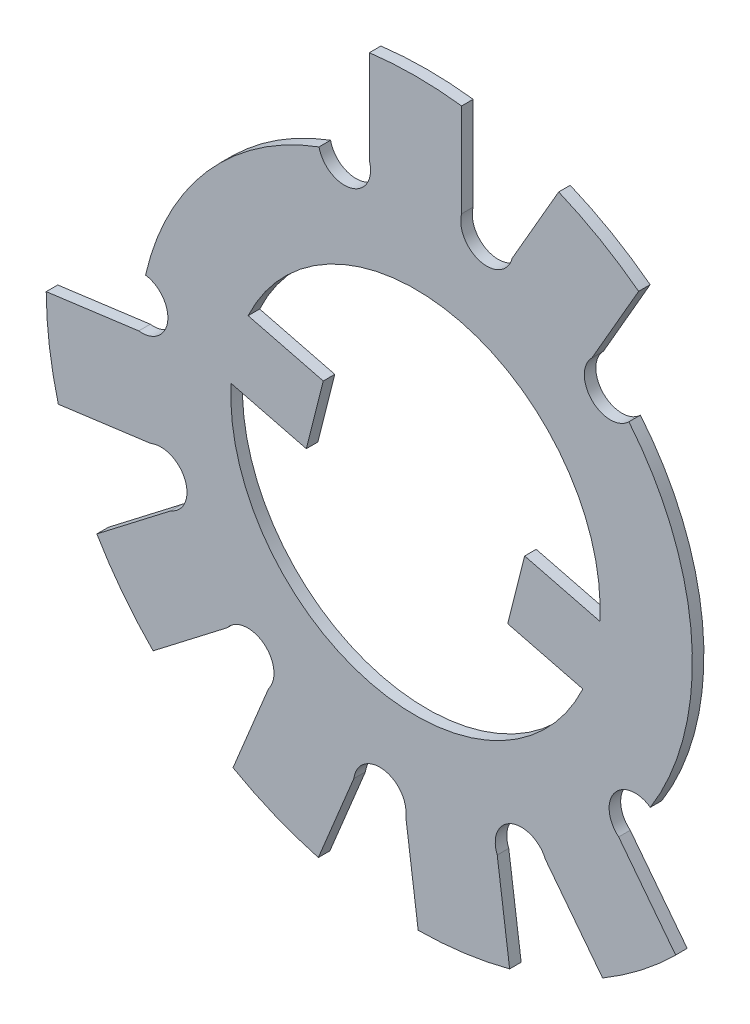
from build123d import *

# Parameters (mm, degrees)
EXTRUSION1_DEPTH = 0.5


with BuildPart() as part:
    # Esquisse1 → Extrusion1 (new body)
    with BuildSketch(Plane.XY):
        with BuildLine():
            Line((1.99912085, 15.874618604), (1.99912085, 11.830127492))
            ThreePointArc((1.99912085, 11.830127492), (2.802057184, 10.445996528), (4.186188149, 11.248932862))
            Line((4.186188149, 11.248932862), (6.205424959, 14.750775921))
            ThreePointArc((6.205424959, 14.750775921), (7.999892198, 13.860780417), (9.669096851, 12.753549413))
            Line((9.669096851, 12.753549413), (7.648767549, 9.249811713))
            ThreePointArc((7.648767549, 9.249811713), (7.645469769, 7.649650968), (9.245630513, 7.646353187))
            ThreePointArc((9.245630513, 7.646353187), (11.971535209, 0.794194802), (10.174683291, -6.358004449))
            ThreePointArc((10.174683291, -6.358004449), (8.622367496, -6.592697054), (8.80279787, -8.152251421))
            Line((8.80279787, -8.152251421), (11.27300937, -11.35198223))
            ThreePointArc((11.27300937, -11.35198223), (9.767202306, -12.672871988), (8.108156612, -13.795267665))
            Line((8.108156612, -13.795267665), (5.636608626, -10.593805669))
            ThreePointArc((5.636608626, -10.593805669), (4.154539047, -9.981087108), (3.541820486, -11.463156687))
            Line((3.541820486, -11.463156687), (4.079298509, -15.469568982))
            ThreePointArc((4.079298509, -15.469568982), (2.114599048, -15.859646786), (0.116557342, -16.00118833))
            Line((0.116557342, -16.00118833), (-0.42121148, -11.9926084))
            ThreePointArc((-0.42121148, -11.9926084), (-1.397751762, -10.720475015), (-2.669885147, -11.697015298))
            Line((-2.669885147, -11.697015298), (-4.209415427, -15.434670796))
            ThreePointArc((-4.209415427, -15.434670796), (-6.105624465, -14.78922835), (-7.906329329, -13.91192187))
            Line((-7.906329329, -13.91192187), (-6.3659661, -10.172244146))
            ThreePointArc((-6.3659661, -10.172244146), (-6.574845101, -8.58217376), (-8.164915488, -8.791052761))
            Line((-8.164915488, -8.791052761), (-11.3681991, -11.256655367))
            ThreePointArc((-11.3681991, -11.256655367), (-12.686919728, -9.748948309), (-13.806925878, -8.088288533))
            Line((-13.806925878, -8.088288533), (-10.601909158, -5.621351934))
            ThreePointArc((-10.601909158, -5.621351934), (-9.987057643, -4.140165962), (-11.468243615, -3.525314447))
            Line((-11.468243615, -3.525314447), (-15.475425513, -4.05702428))
            ThreePointArc((-15.475425513, -4.05702428), (-15.86267453, -2.091765297), (-16.001339545, -0.093521899))
            Line((-16.001339545, -0.093521899), (-11.991989597, 0.438475611))
            ThreePointArc((-11.991989597, 0.438475611), (-10.737924032, 1.413097931), (-11.69713727, 2.678988555))
            ThreePointArc((-11.69713727, 2.678988555), (-9.021028947, 7.913345483), (-4.179870655, 11.248496846))
            ThreePointArc((-4.179870655, 11.248496846), (-2.783654446, 10.397988514), (-1.99912085, 11.832314545))
            Line((-1.99912085, 11.832314545), (-1.99912085, 15.874618604))
            ThreePointArc((-1.99912085, 15.874618604), (0, 16), (1.99912085, 15.874618604))
        make_face()
        with BuildLine():
            Line((7.986234295, -0.469107442), (4.730272388, 0.352878359))
            Line((4.730272388, 0.352878359), (3.995944926, -2.555860746))
            Line((3.995944926, -2.555860746), (7.251906832, -3.377846547))
            ThreePointArc((7.251906832, -3.377846547), (-1.958206566, -7.756637612), (-7.986234295, 0.469107442))
            Line((-7.986234295, 0.469107442), (-4.730272388, -0.352878359))
            Line((-4.730272388, -0.352878359), (-3.995944926, 2.555860746))
            Line((-3.995944926, 2.555860746), (-7.251906832, 3.377846547))
            ThreePointArc((-7.251906832, 3.377846547), (1.958206566, 7.756637612), (7.986234295, -0.469107442))
        make_face(mode=Mode.SUBTRACT)
    extrude(amount=EXTRUSION1_DEPTH)


solid = part.part
